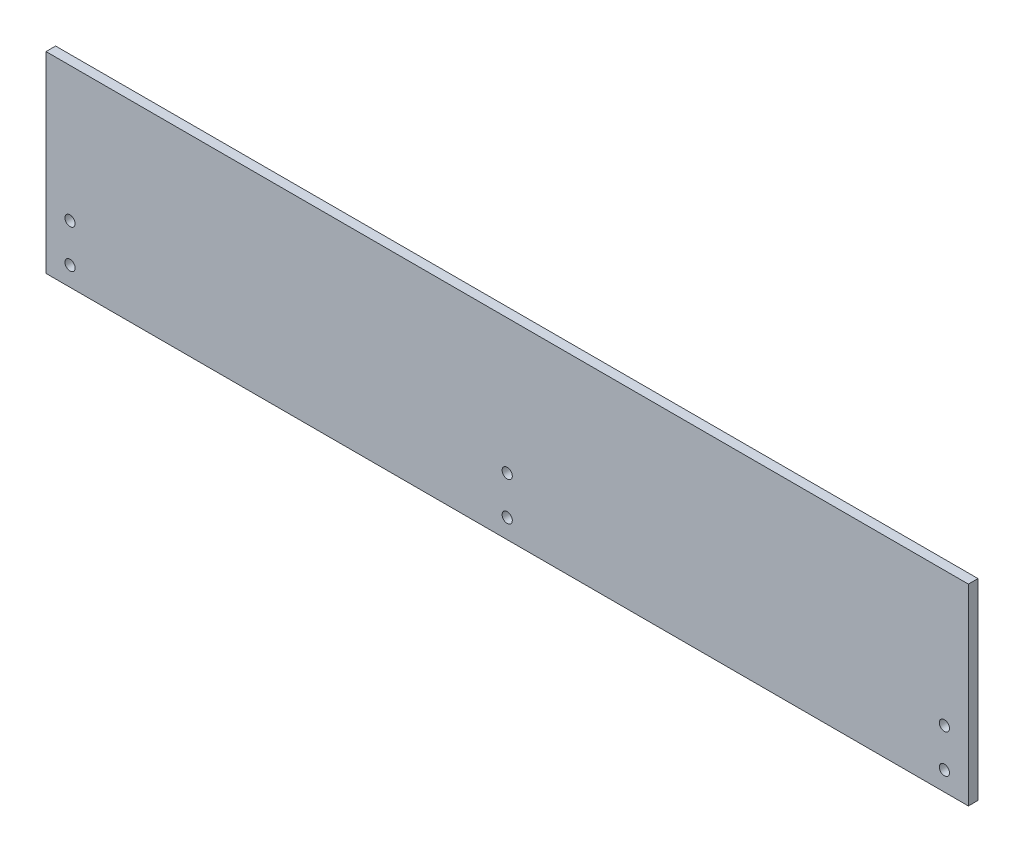
from build123d import *

# Parameters (mm, degrees)
SKETCH2_W           = 609.6
SKETCH2_H           = 127
BOSS_EXTRUDE1_DEPTH = 6.35
SKETCH3_R           = 3.3655
CUT_EXTRUDE1_DEPTH  = 6.35
SKETCH6_R           = 3.3655
CUT_EXTRUDE4_DEPTH  = 7.35


with BuildPart() as part:
    # Sketch2 → Boss-Extrude1 (new body)
    with BuildSketch(Plane.XY):
        with Locations((304.8, 63.5)):
            Rectangle(SKETCH2_W, SKETCH2_H)
    extrude(amount=BOSS_EXTRUDE1_DEPTH)

    # Sketch3 → Cut-Extrude1 (cut)
    with BuildSketch(Plane.XY.offset(6.35)):
        with Locations((15.875, 12.7)):
            Circle(SKETCH3_R)
        with Locations((593.725, 12.7)):
            Circle(SKETCH3_R)
        with Locations((593.725, 38.1)):
            Circle(SKETCH3_R)
        with Locations((15.875, 38.1)):
            Circle(SKETCH3_R)
    extrude(amount=-CUT_EXTRUDE1_DEPTH, mode=Mode.SUBTRACT)

    # Sketch6 → Cut-Extrude4 (cut, through all)
    with BuildSketch(Plane.XY.offset(6.35)):
        with Locations((304.8, 38.1)):
            Circle(SKETCH6_R)
        with Locations((304.8, 12.7)):
            Circle(SKETCH6_R)
    extrude(amount=-CUT_EXTRUDE4_DEPTH, mode=Mode.SUBTRACT)


solid = part.part
